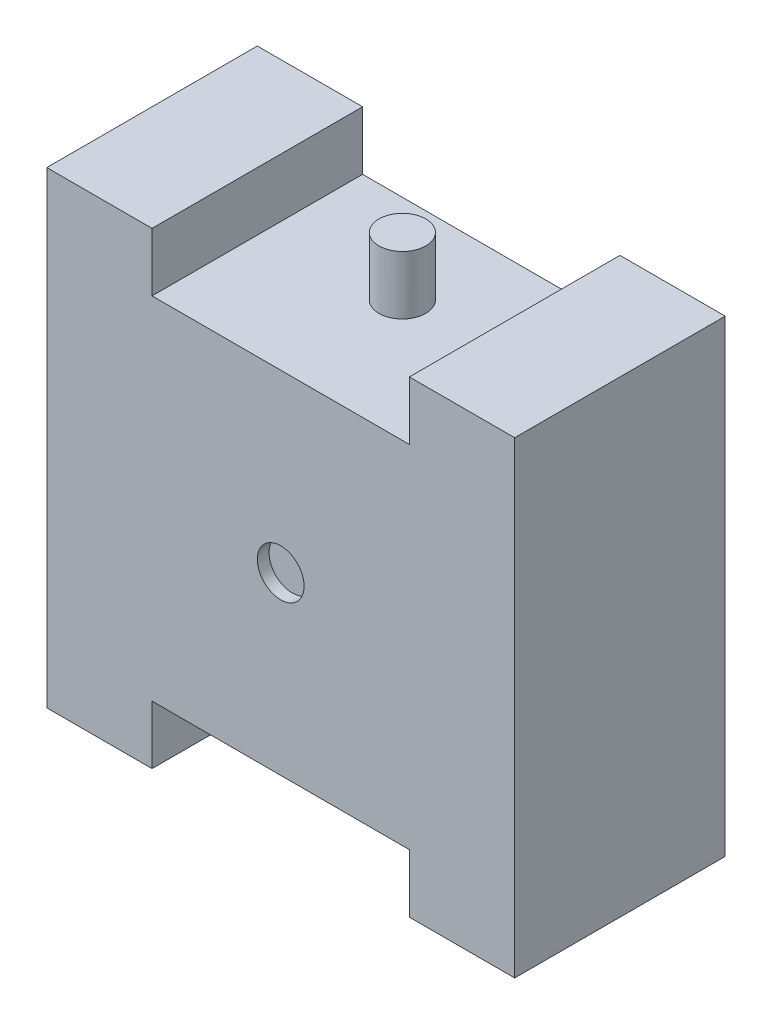
from build123d import *

# Parameters (mm, degrees)
BOSS_EXTRUDE1_DEPTH = 450
SKETCH2_R           = 50
BOSS_EXTRUDE2_DEPTH = 125
SKETCH3_R           = 50
BOSS_EXTRUDE3_DEPTH = 125
SKETCH4_R           = 50
CUT_EXTRUDE1_DEPTH  = 25
SKETCH5_W           = 100
SKETCH5_H           = 100
CUT_EXTRUDE2_DEPTH  = 25


with BuildPart() as part:
    # Sketch1 → Boss-Extrude1 (new body)
    with BuildSketch(Plane.XY):
        Polygon((-275, 500), (-275, 375), (275, 375), (275, 500), (500, 500), (500, -500), (275, -500), (275, -375), (-275, -375), (-275, -500), (-500, -500), (-500, 500), align=None)
    extrude(amount=BOSS_EXTRUDE1_DEPTH)

    # Sketch2 → Boss-Extrude2 (add)
    with BuildSketch(Plane.XZ.offset(375)):
        with Locations((0, 190)):
            Circle(SKETCH2_R)
    extrude(amount=BOSS_EXTRUDE2_DEPTH)

    # Sketch3 → Boss-Extrude3 (add)
    with BuildSketch(Plane(origin=(0, 375, 0), x_dir=(1, 0, 0), z_dir=(0, 1, 0))):
        with Locations((0, -190)):
            Circle(SKETCH3_R)
    extrude(amount=BOSS_EXTRUDE3_DEPTH)

    # Sketch4 → Cut-Extrude1 (cut)
    with BuildSketch(Plane.XY.offset(450)):
        Circle(SKETCH4_R)
    extrude(amount=-CUT_EXTRUDE1_DEPTH, mode=Mode.SUBTRACT)

    # Sketch5 → Cut-Extrude2 (cut)
    with BuildSketch(Plane(origin=(0, 0, 0), x_dir=(-1, 0, 0), z_dir=(0, 0, -1))):
        with Locations((350, 0)):
            Rectangle(SKETCH5_W, SKETCH5_H)
        with Locations((-350, 0)):
            Rectangle(SKETCH5_W, SKETCH5_H)
    extrude(amount=-CUT_EXTRUDE2_DEPTH, mode=Mode.SUBTRACT)


solid = part.part
